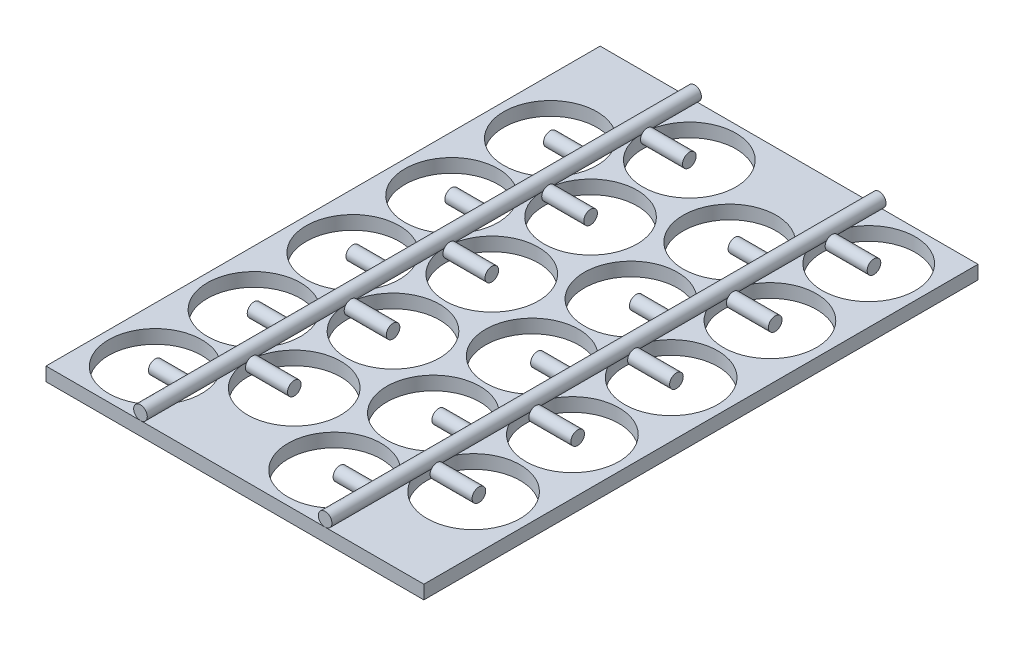
from build123d import *

# Parameters (mm, degrees)
SKETCH1_W           = 88
SKETCH1_H           = 129.049998998
SKETCH1_R           = 10.85
BOSS_EXTRUDE2_DEPTH = 3.175
SKETCH2_R           = 1.5875
BOSS_EXTRUDE3_DEPTH = 129.049999
SKETCH4_W           = 9.78730207
SKETCH4_H           = 1.5875
SKETCH7_W           = 7.5625
SKETCH7_H           = 1.5875
LPATTERN2_COUNT     = 5
LPATTERN2_PITCH     = 23
LPATTERN3_COUNT     = 5
LPATTERN3_PITCH     = 23
LPATTERN4_COUNT     = 2
LPATTERN4_PITCH     = 43


with BuildPart() as part:
    # Sketch1 → Boss-Extrude2 (new body)
    with BuildSketch(Plane(origin=(0, 0, 0), x_dir=(1, 0, 0), z_dir=(0, 1, 0))):
        with Locations((22, 0)):
            Rectangle(SKETCH1_W, SKETCH1_H)
        with Locations((-9.169208279, -51.924999499)):
            Circle(SKETCH1_R, mode=Mode.SUBTRACT)
        with Locations((11.355593791, -40.074999499)):
            Circle(SKETCH1_R, mode=Mode.SUBTRACT)
        with Locations((-9.164406209, -28.924999749)):
            Circle(SKETCH1_R, mode=Mode.SUBTRACT)
        with Locations((-9.159604139, -5.925)):
            Circle(SKETCH1_R, mode=Mode.SUBTRACT)
        with Locations((11.360395861, -17.074999749)):
            Circle(SKETCH1_R, mode=Mode.SUBTRACT)
        with Locations((32.605989652, -51.924999499)):
            Circle(SKETCH1_R, mode=Mode.SUBTRACT)
        with Locations((53.130791721, -40.074999499)):
            Circle(SKETCH1_R, mode=Mode.SUBTRACT)
        with Locations((32.610791721, -28.924999749)):
            Circle(SKETCH1_R, mode=Mode.SUBTRACT)
        with Locations((32.615593791, -5.925)):
            Circle(SKETCH1_R, mode=Mode.SUBTRACT)
        with Locations((53.135593791, -17.074999749)):
            Circle(SKETCH1_R, mode=Mode.SUBTRACT)
        with Locations((-9.15480207, 17.074999749)):
            Circle(SKETCH1_R, mode=Mode.SUBTRACT)
        with Locations((11.36519793, 5.925)):
            Circle(SKETCH1_R, mode=Mode.SUBTRACT)
        with Locations((11.37, 28.924999749)):
            Circle(SKETCH1_R, mode=Mode.SUBTRACT)
        with Locations((-9.15, 40.074999499)):
            Circle(SKETCH1_R, mode=Mode.SUBTRACT)
        with Locations((11.37480207, 51.924999499)):
            Circle(SKETCH1_R, mode=Mode.SUBTRACT)
        with Locations((32.620395861, 17.074999749)):
            Circle(SKETCH1_R, mode=Mode.SUBTRACT)
        with Locations((53.140395861, 5.925)):
            Circle(SKETCH1_R, mode=Mode.SUBTRACT)
        with Locations((53.14519793, 28.924999749)):
            Circle(SKETCH1_R, mode=Mode.SUBTRACT)
        with Locations((32.62519793, 40.074999499)):
            Circle(SKETCH1_R, mode=Mode.SUBTRACT)
        with Locations((53.15, 51.924999499)):
            Circle(SKETCH1_R, mode=Mode.SUBTRACT)
    extrude(amount=BOSS_EXTRUDE2_DEPTH)


with BuildPart() as body_2:
    # Sketch2 → Boss-Extrude3 (new body)
    with BuildSketch(Plane.XY.offset(64.524999499)):
        with Locations((0, 4.7625)):
            Circle(SKETCH2_R)
    extrude(amount=-BOSS_EXTRUDE3_DEPTH)


with BuildPart() as body_3:
    # Sketch4 → Revolve3 (revolve)
    with BuildSketch(Plane(origin=(0, 3.175, 0), x_dir=(1, 0, 0), z_dir=(0, 1, 0))):
        with Locations((6.481151035, 52.718749499)):
            Rectangle(SKETCH4_W, SKETCH4_H)
    revolve(axis=Axis((11.37480207, 3.175, -51.924999499), (-1, 0, 0)))


with BuildPart() as body_4:
    # Sketch7 → Revolve4 (revolve)
    with BuildSketch(Plane(origin=(0, 3.175, 0), x_dir=(1, 0, 0), z_dir=(0, 1, 0))):
        with Locations((-5.36875, 40.868749499)):
            Rectangle(SKETCH7_W, SKETCH7_H)
    revolve(axis=Axis((-9.15, 3.175, -40.074999499), (1, 0, 0)))


with BuildPart() as lpattern2_1:
    # LPattern2: pattern copy
    add(body_4.part.moved(Location(Vector(0, 0, 1) * (1 * LPATTERN2_PITCH))))


with BuildPart() as lpattern2_2:
    # LPattern2: pattern copy
    add(body_4.part.moved(Location(Vector(0, 0, 1) * (2 * LPATTERN2_PITCH))))


with BuildPart() as lpattern2_3:
    # LPattern2: pattern copy
    add(body_4.part.moved(Location(Vector(0, 0, 1) * (3 * LPATTERN2_PITCH))))


with BuildPart() as lpattern2_4:
    # LPattern2: pattern copy
    add(body_4.part.moved(Location(Vector(0, 0, 1) * (4 * LPATTERN2_PITCH))))


with BuildPart() as lpattern3_1:
    # LPattern3: pattern copy
    add(body_3.part.moved(Location(Vector(0, 0, 1) * (1 * LPATTERN3_PITCH))))


with BuildPart() as lpattern3_2:
    # LPattern3: pattern copy
    add(body_3.part.moved(Location(Vector(0, 0, 1) * (2 * LPATTERN3_PITCH))))


with BuildPart() as lpattern3_3:
    # LPattern3: pattern copy
    add(body_3.part.moved(Location(Vector(0, 0, 1) * (3 * LPATTERN3_PITCH))))


with BuildPart() as lpattern3_4:
    # LPattern3: pattern copy
    add(body_3.part.moved(Location(Vector(0, 0, 1) * (4 * LPATTERN3_PITCH))))


with BuildPart() as lpattern4_1:
    # LPattern4: pattern copy
    add(lpattern2_4.part.moved(Location(Vector(1, 0, 0) * (1 * LPATTERN4_PITCH))))


with BuildPart() as lpattern4_2:
    # LPattern4: pattern copy
    add(lpattern3_4.part.moved(Location(Vector(1, 0, 0) * (1 * LPATTERN4_PITCH))))


with BuildPart() as lpattern4_3:
    # LPattern4: pattern copy
    add(lpattern2_3.part.moved(Location(Vector(1, 0, 0) * (1 * LPATTERN4_PITCH))))


with BuildPart() as lpattern4_4:
    # LPattern4: pattern copy
    add(lpattern3_3.part.moved(Location(Vector(1, 0, 0) * (1 * LPATTERN4_PITCH))))


with BuildPart() as lpattern4_5:
    # LPattern4: pattern copy
    add(lpattern2_2.part.moved(Location(Vector(1, 0, 0) * (1 * LPATTERN4_PITCH))))


with BuildPart() as lpattern4_6:
    # LPattern4: pattern copy
    add(lpattern3_2.part.moved(Location(Vector(1, 0, 0) * (1 * LPATTERN4_PITCH))))


with BuildPart() as lpattern4_7:
    # LPattern4: pattern copy
    add(lpattern2_1.part.moved(Location(Vector(1, 0, 0) * (1 * LPATTERN4_PITCH))))


with BuildPart() as lpattern4_8:
    # LPattern4: pattern copy
    add(lpattern3_1.part.moved(Location(Vector(1, 0, 0) * (1 * LPATTERN4_PITCH))))


with BuildPart() as lpattern4_9:
    # LPattern4: pattern copy
    add(body_2.part.moved(Location(Vector(1, 0, 0) * (1 * LPATTERN4_PITCH))))


with BuildPart() as lpattern4_10:
    # LPattern4: pattern copy
    add(body_3.part.moved(Location(Vector(1, 0, 0) * (1 * LPATTERN4_PITCH))))


with BuildPart() as lpattern4_11:
    # LPattern4: pattern copy
    add(body_4.part.moved(Location(Vector(1, 0, 0) * (1 * LPATTERN4_PITCH))))


solid = Compound([part.part, body_2.part, body_3.part, body_4.part, lpattern2_1.part, lpattern2_2.part, lpattern2_3.part, lpattern2_4.part, lpattern3_1.part, lpattern3_2.part, lpattern3_3.part, lpattern3_4.part, lpattern4_1.part, lpattern4_2.part, lpattern4_3.part, lpattern4_4.part, lpattern4_5.part, lpattern4_6.part, lpattern4_7.part, lpattern4_8.part, lpattern4_9.part, lpattern4_10.part, lpattern4_11.part])
